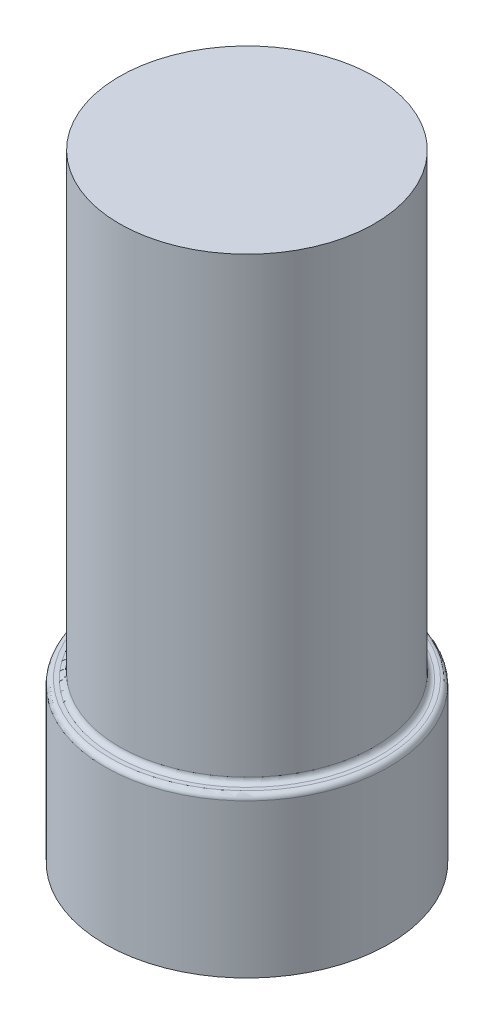
from build123d import *

# Parameters (mm, degrees)
SKETCH1_R           = 13.75
BOSS_EXTRUDE1_DEPTH = 15.35
SKETCH2_R           = 12.35
BOSS_EXTRUDE2_DEPTH = 44.35
FILLET1_R           = 0.5
SKETCH3_R           = 2.8
CUT_EXTRUDE1_DEPTH  = 3
SKETCH4_R           = 0.5
BOSS_EXTRUDE3_DEPTH = 2.5
CHAMFER1_SIZE       = 0.5


with BuildPart() as part:
    # Sketch1 → Boss-Extrude1 (new body)
    with BuildSketch(Plane(origin=(0, 0, 0), x_dir=(1, 0, 0), z_dir=(0, 1, 0))):
        Circle(SKETCH1_R)
    extrude(amount=BOSS_EXTRUDE1_DEPTH)

    # Sketch2 → Boss-Extrude2 (add)
    with BuildSketch(Plane(origin=(0, 15.35, 0), x_dir=(1, 0, 0), z_dir=(0, 1, 0))):
        Circle(SKETCH2_R)
    extrude(amount=BOSS_EXTRUDE2_DEPTH)

    # Fillet1
    fillet1_edges = [part.edges().sort_by_distance(p)[0] for p in [
        (-13.75, 15.35, 0),
        (-12.35, 15.35, 0),
    ]]
    fillet(fillet1_edges, radius=FILLET1_R)

    # Sketch3 → Cut-Extrude1 (cut)
    with BuildSketch(Plane.XZ):
        Circle(SKETCH3_R)
    extrude(amount=-CUT_EXTRUDE1_DEPTH, mode=Mode.SUBTRACT)

    # Sketch4 → Boss-Extrude3 (add)
    with BuildSketch(Plane.XZ.offset(-3)):
        Circle(SKETCH4_R)
    extrude(amount=BOSS_EXTRUDE3_DEPTH)

    # Chamfer1
    chamfer1_edges = [part.edges().sort_by_distance(p)[0] for p in [
        (-0.5, 0.5, 0),
    ]]
    chamfer(chamfer1_edges, length=CHAMFER1_SIZE)


solid = part.part
